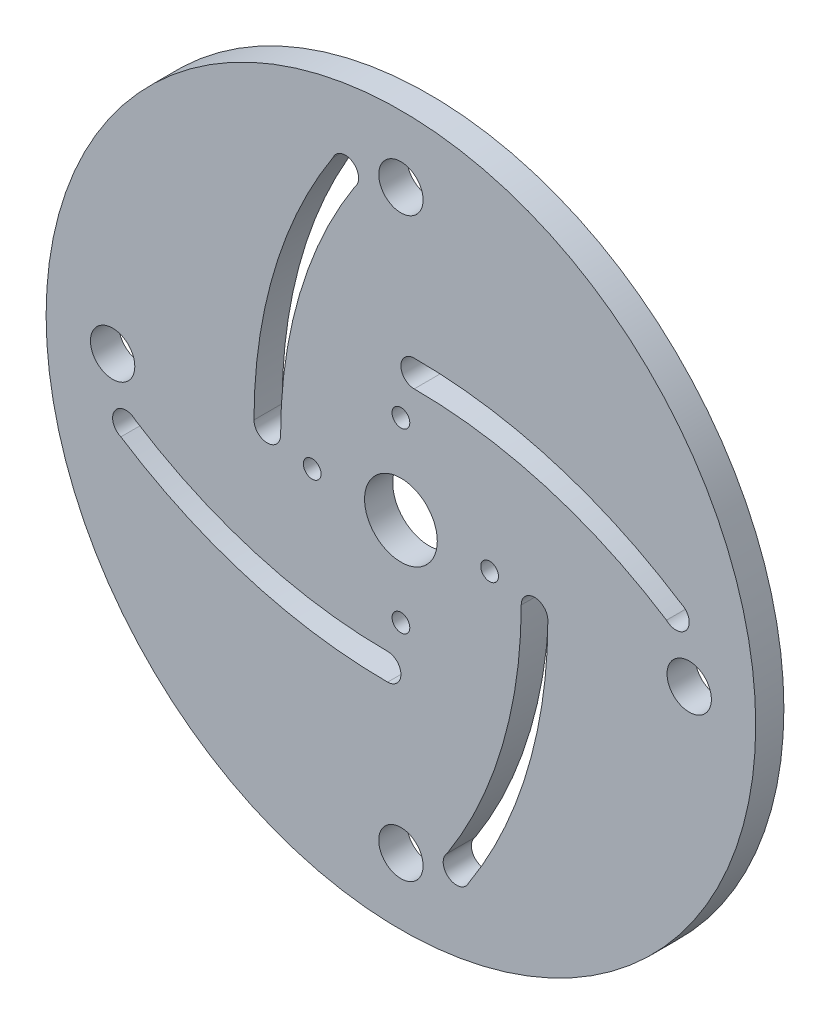
from build123d import *

# Parameters (mm, degrees)
SKETCH1_R           = 40
SKETCH1_R_2         = 4.1
SKETCH1_R_3         = 1
SKETCH1_R_4         = 2.5
BOSS_EXTRUDE1_DEPTH = 3.175


with BuildPart() as part:
    # Sketch1 → Boss-Extrude1 (new body)
    with BuildSketch(Plane.XY):
        Circle(SKETCH1_R)
        Circle(SKETCH1_R_2, mode=Mode.SUBTRACT)
        with Locations((10, 0)):
            Circle(SKETCH1_R_3, mode=Mode.SUBTRACT)
        with Locations((0, -10)):
            Circle(SKETCH1_R_3, mode=Mode.SUBTRACT)
        with Locations((-10, 0)):
            Circle(SKETCH1_R_3, mode=Mode.SUBTRACT)
        with Locations((0, 10)):
            Circle(SKETCH1_R_3, mode=Mode.SUBTRACT)
        with Locations((0, 32.500000024)):
            Circle(SKETCH1_R_4, mode=Mode.SUBTRACT)
        with Locations((32.500000024, 0)):
            Circle(SKETCH1_R_4, mode=Mode.SUBTRACT)
        with Locations((0, -32.500000024)):
            Circle(SKETCH1_R_4, mode=Mode.SUBTRACT)
        with Locations((-32.500000024, 0)):
            Circle(SKETCH1_R_4, mode=Mode.SUBTRACT)
        with BuildLine():
            ThreePointArc((1.5, 16.564017782), (17.18320836, 14.289419004), (31.574025173, 7.653063411))
            ThreePointArc((31.574025173, 7.653063411), (32.247204442, 5.433888763), (29.939339852, 5.206583941))
            ThreePointArc((29.939339852, 5.206583941), (16.320954352, 11.431399277), (1.5, 13.564017782))
            ThreePointArc((1.5, 13.564017782), (0, 15.064017782), (1.5, 16.564017782))
        make_face(mode=Mode.SUBTRACT)
        with BuildLine():
            ThreePointArc((16.564017782, -1.5), (14.289419004, -17.18320836), (7.653063411, -31.574025173))
            ThreePointArc((7.653063411, -31.574025173), (5.433888763, -32.247204442), (5.206583941, -29.939339852))
            ThreePointArc((5.206583941, -29.939339852), (11.431399277, -16.320954352), (13.564017782, -1.5))
            ThreePointArc((13.564017782, -1.5), (15.064017782, 0), (16.564017782, -1.5))
        make_face(mode=Mode.SUBTRACT)
        with BuildLine():
            ThreePointArc((-1.5, -16.564017782), (-17.18320836, -14.289419004), (-31.574025173, -7.653063411))
            ThreePointArc((-31.574025173, -7.653063411), (-32.247204442, -5.433888763), (-29.939339852, -5.206583941))
            ThreePointArc((-29.939339852, -5.206583941), (-16.320954352, -11.431399277), (-1.5, -13.564017782))
            ThreePointArc((-1.5, -13.564017782), (0, -15.064017782), (-1.5, -16.564017782))
        make_face(mode=Mode.SUBTRACT)
        with BuildLine():
            ThreePointArc((-16.564017782, 1.5), (-14.289419004, 17.18320836), (-7.653063411, 31.574025173))
            ThreePointArc((-7.653063411, 31.574025173), (-5.433888763, 32.247204442), (-5.206583941, 29.939339852))
            ThreePointArc((-5.206583941, 29.939339852), (-11.431399277, 16.320954352), (-13.564017782, 1.5))
            ThreePointArc((-13.564017782, 1.5), (-15.064017782, 0), (-16.564017782, 1.5))
        make_face(mode=Mode.SUBTRACT)
    extrude(amount=BOSS_EXTRUDE1_DEPTH)


solid = part.part
